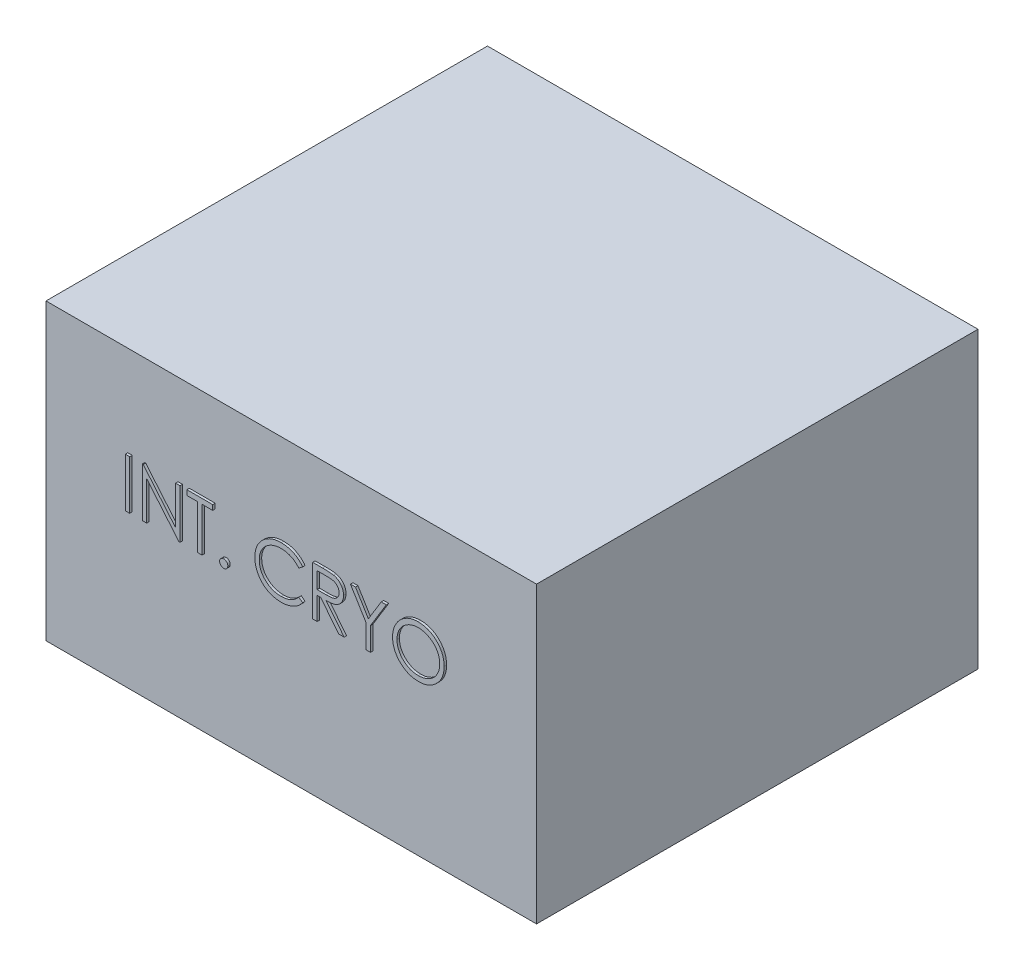
from build123d import *

# Parameters (mm, degrees)
SKETCH1_W           = 1000
SKETCH1_H           = 600
BOSS_EXTRUDE1_DEPTH = 900
SKETCH2_W           = 8.974358974
SKETCH2_H           = 100
BOSS_EXTRUDE2_DEPTH = 5


with BuildPart() as part:
    # Sketch1 → Boss-Extrude1 (new body)
    with BuildSketch(Plane.XY):
        with Locations((-500, -300)):
            Rectangle(SKETCH1_W, SKETCH1_H)
    extrude(amount=BOSS_EXTRUDE1_DEPTH)

    # Sketch2 → Boss-Extrude2 (add)
    with BuildSketch(Plane.XY.offset(900)):
        with Locations((-828.846153846, -234.669187655)):
            Rectangle(SKETCH2_W, SKETCH2_H)
        Polygon((-798.717948718, -284.669187655), (-798.717948718, -184.669187655), (-796.834935897, -184.669187655), (-730.769230769, -263.375117142), (-730.769230769, -184.669187655), (-721.794871795, -184.669187655), (-721.794871795, -284.669187655), (-723.838141026, -284.669187655), (-789.743589744, -206.143546629), (-789.743589744, -284.669187655), align=None)
        Polygon((-707.692307692, -194.925597911), (-707.692307692, -184.669187655), (-655.128205128, -184.669187655), (-655.128205128, -194.925597911), (-676.923076923, -194.925597911), (-676.923076923, -284.669187655), (-685.897435897, -284.669187655), (-685.897435897, -194.925597911), align=None)
        with BuildLine():
            add(Edge.make_bspline(
                [(-632.692307692, -269.28457227), (-632.135444487, -269.317662747), (-631.043779276, -269.382532758), (-629.465518467, -269.82758058), (-628.037099618, -270.617828022), (-626.764749767, -271.671050261), (-625.715993295, -272.948069207), (-624.897583234, -274.365095171), (-624.456412228, -275.956569245), (-624.392014748, -277.054559958), (-624.358974359, -277.617905603)],
                knots=[0, 0, 0, 0, 0.001670366, 0.003274556, 0.004870094, 0.006534684, 0.008199274, 0.009804465, 0.011408656, 0.013098962, 0.013098962, 0.013098962, 0.013098962], degree=3))
            add(Edge.make_bspline(
                [(-624.358974359, -277.617905603), (-624.39313438, -278.167715025), (-624.460497441, -279.251931131), (-624.896571959, -280.831401491), (-625.722230537, -282.249313048), (-626.757516049, -283.543659851), (-628.03741415, -284.599113297), (-629.468895477, -285.382637432), (-631.040074281, -285.859551144), (-632.134826377, -285.92030249), (-632.692307692, -285.951238937)],
                knots=[0, 0, 0, 0, 0.001650427, 0.003254618, 0.004859809, 0.006539876, 0.008204466, 0.009800004, 0.011409813, 0.013080178, 0.013080178, 0.013080178, 0.013080178], degree=3))
            add(Edge.make_bspline(
                [(-632.692307692, -285.951238937), (-633.250190711, -285.921421875), (-634.3393245, -285.863211159), (-635.904638621, -285.372845265), (-637.344837723, -284.606460687), (-638.62448663, -283.541691844), (-639.668442961, -282.255973462), (-640.457739614, -280.821636421), (-640.93174387, -279.256452495), (-640.994083089, -278.168605556), (-641.025641026, -277.617905603)],
                knots=[0, 0, 0, 0, 0.001670366, 0.003260991, 0.004874162, 0.006538752, 0.008218819, 0.009814357, 0.011424166, 0.013074593, 0.013074593, 0.013074593, 0.013074593], degree=3))
            add(Edge.make_bspline(
                [(-641.025641026, -277.617905603), (-640.995295333, -277.053637614), (-640.936049091, -275.951973614), (-640.456744513, -274.374856257), (-639.67456703, -272.941472278), (-638.61727003, -271.672998561), (-637.34514729, -270.610504199), (-635.908112857, -269.837224395), (-634.335554562, -269.378926904), (-633.249556322, -269.316569282), (-632.692307692, -269.28457227)],
                knots=[0, 0, 0, 0, 0.001690306, 0.003300116, 0.004895653, 0.006560243, 0.008224833, 0.009838004, 0.011422943, 0.013093309, 0.013093309, 0.013093309, 0.013093309], degree=3))
        make_face()
        with BuildLine():
            Line((-471.794871795, -203.018546629), (-479.647435897, -209.028162014))
            add(Edge.make_bspline(
                [(-479.647435897, -209.028162014), (-480.207604136, -208.360562876), (-481.320388331, -207.034365284), (-483.11065126, -205.172092584), (-484.976412486, -203.427370829), (-486.916958806, -201.791888554), (-488.967219363, -200.322838105), (-491.077527897, -198.943663735), (-493.283186331, -197.707442651), (-496.333235892, -196.20850019), (-500.323174415, -194.644324333), (-505.345884102, -193.332803439), (-510.589058345, -192.497912705), (-514.16613262, -192.407488663), (-515.985576923, -192.361495347)],
                knots=[0, 0, 0, 0, 0.002613856, 0.005192473, 0.007743552, 0.010275052, 0.012799409, 0.015305337, 0.017834775, 0.020379083, 0.025497771, 0.030657998, 0.035927608, 0.041382546, 0.041382546, 0.041382546, 0.041382546], degree=3))
            add(Edge.make_bspline(
                [(-515.985576923, -192.361495347), (-516.987956904, -192.373037133), (-518.983413835, -192.396013586), (-521.944798792, -192.699131449), (-524.850885967, -193.125166022), (-527.699785002, -193.757318114), (-530.487869532, -194.556535802), (-533.233366734, -195.511547628), (-535.896526728, -196.693114482), (-538.514190677, -197.999064766), (-541.022168134, -199.474134616), (-543.395169499, -201.083087527), (-545.624540011, -202.807918854), (-547.712043215, -204.655093322), (-549.659813167, -206.616292192), (-551.453736333, -208.712416238), (-553.087605198, -210.936764053), (-554.593805914, -213.260004268), (-555.942741152, -215.675369744), (-557.072166278, -218.191800328), (-558.072312627, -220.766203271), (-558.863719559, -223.427665009), (-559.490134326, -226.157458319), (-559.922353277, -228.962909404), (-560.222023882, -231.838157392), (-560.244886079, -233.786994895), (-560.256410256, -234.769347911)],
                knots=[0, 0, 0, 0, 0.003005876, 0.005983854, 0.008921744, 0.011813723, 0.014730434, 0.017619498, 0.020526078, 0.023464515, 0.026391663, 0.029247478, 0.032060323, 0.034841822, 0.037603994, 0.040346045, 0.04311054, 0.045877648, 0.048648306, 0.051400362, 0.054145923, 0.056928071, 0.059722309, 0.062541424, 0.065439641, 0.068385442, 0.068385442, 0.068385442, 0.068385442], degree=3))
            add(Edge.make_bspline(
                [(-560.256410256, -234.769347911), (-560.220358284, -236.247385623), (-560.149575019, -239.149316619), (-559.519622617, -243.399905492), (-558.562334294, -247.471924742), (-557.127603525, -251.339920237), (-555.358487794, -255.05158761), (-553.123041751, -258.544126279), (-550.533997827, -261.870313836), (-547.554728699, -264.951540915), (-544.2859911, -267.76621878), (-540.778907911, -270.244806824), (-537.042213974, -272.310946323), (-533.117167398, -274.03025908), (-528.973564143, -275.35187987), (-524.618855502, -276.282283399), (-520.062512781, -276.889202843), (-516.949101356, -276.947308217), (-515.364583333, -276.976879962)],
                knots=[0, 0, 0, 0, 0.004431613, 0.008700885, 0.012864709, 0.016958508, 0.021052943, 0.025176628, 0.029372183, 0.03367912, 0.038011651, 0.042296543, 0.046538138, 0.050799366, 0.055132591, 0.059560761, 0.064144995, 0.068896013, 0.068896013, 0.068896013, 0.068896013], degree=3))
            add(Edge.make_bspline(
                [(-515.364583333, -276.976879962), (-513.618792219, -276.928629112), (-510.182657679, -276.833659897), (-505.143571212, -276.029109922), (-500.319692194, -274.724597984), (-495.71076115, -272.898943061), (-491.329771258, -270.52564912), (-487.169866678, -267.648566909), (-483.227536092, -264.24032883), (-480.856928028, -261.637953737), (-479.647435897, -260.310213296)],
                knots=[0, 0, 0, 0, 0.005234847, 0.010303431, 0.015264994, 0.020201259, 0.0251398, 0.030179682, 0.035348806, 0.040733293, 0.040733293, 0.040733293, 0.040733293], degree=3))
            Line((-479.647435897, -260.310213296), (-471.794871795, -266.259732527))
            add(Edge.make_bspline(
                [(-471.794871795, -266.259732527), (-472.426817791, -267.075116867), (-473.687682799, -268.701979904), (-475.729340427, -270.995457324), (-477.880120353, -273.152715481), (-480.155997782, -275.156361802), (-482.530791827, -277.046489391), (-485.047143608, -278.769398856), (-487.671973108, -280.349138407), (-490.396386791, -281.795621964), (-493.217490014, -283.078971879), (-496.131902441, -284.177650959), (-499.127061741, -285.124076374), (-502.203104839, -285.902703138), (-505.366412177, -286.510448391), (-508.605568579, -286.916724816), (-511.927565014, -287.195065228), (-514.168748475, -287.220434251), (-515.304487179, -287.233290219)],
                knots=[0, 0, 0, 0, 0.003094093, 0.006173365, 0.009204632, 0.012227349, 0.015265161, 0.018304559, 0.021369005, 0.024451598, 0.027553463, 0.030660046, 0.033789793, 0.036972117, 0.040174051, 0.043446395, 0.046761927, 0.050168318, 0.050168318, 0.050168318, 0.050168318], degree=3))
            add(Edge.make_bspline(
                [(-515.304487179, -287.233290219), (-516.380020524, -287.225804717), (-518.506754527, -287.211003065), (-521.646718859, -286.971226853), (-524.703564024, -286.644091513), (-527.668553335, -286.15151634), (-530.557866908, -285.570249481), (-533.345312179, -284.79107072), (-536.058318189, -283.918237389), (-538.685985066, -282.892380625), (-541.230547917, -281.734775409), (-543.683799671, -280.426445155), (-546.044612025, -278.978391879), (-548.336195478, -277.422534438), (-550.524697869, -275.708897242), (-552.629084307, -273.861279113), (-554.661155057, -271.885907378), (-555.918374628, -270.461482996), (-556.550480769, -269.74530945)],
                knots=[0, 0, 0, 0, 0.00322572, 0.006378462, 0.009442318, 0.01244579, 0.015392341, 0.018278973, 0.021123312, 0.023939366, 0.026736187, 0.029505324, 0.032274388, 0.035041423, 0.037810342, 0.040606877, 0.043439979, 0.046304772, 0.046304772, 0.046304772, 0.046304772], degree=3))
            add(Edge.make_bspline(
                [(-556.550480769, -269.74530945), (-557.562927726, -268.501275481), (-559.575598493, -266.028226612), (-562.150618023, -262.020055719), (-564.354833886, -257.835249751), (-566.137003051, -253.451823214), (-567.530223998, -248.87961215), (-568.495401001, -244.116311739), (-569.1225897, -239.166370533), (-569.194312237, -235.799605142), (-569.230769231, -234.088258168)],
                knots=[0, 0, 0, 0, 0.004808736, 0.009559416, 0.014263537, 0.018980436, 0.023733143, 0.028581148, 0.033545542, 0.038677658, 0.038677658, 0.038677658, 0.038677658], degree=3))
            add(Edge.make_bspline(
                [(-569.230769231, -234.088258168), (-569.186335129, -232.289530924), (-569.098913808, -228.750647365), (-568.356176795, -223.557105842), (-567.161354046, -218.581351589), (-565.464300087, -213.832673172), (-563.312718621, -209.286093737), (-560.654815368, -204.976345027), (-557.521468447, -200.875865037), (-553.937252228, -197.046872143), (-550.006756934, -193.545747782), (-545.797647965, -190.465570532), (-541.318163766, -187.902212932), (-536.617653718, -185.759465434), (-531.660919959, -184.112480773), (-526.458537984, -182.959532582), (-521.020283276, -182.241900688), (-517.309928258, -182.151180462), (-515.424679487, -182.105085091)],
                knots=[0, 0, 0, 0, 0.005393981, 0.010612321, 0.015704128, 0.020722226, 0.025713143, 0.03076698, 0.035883355, 0.041170033, 0.046476826, 0.051653668, 0.056787035, 0.06193305, 0.067127496, 0.072424753, 0.077898527, 0.083552677, 0.083552677, 0.083552677, 0.083552677], degree=3))
            add(Edge.make_bspline(
                [(-515.424679487, -182.105085091), (-514.275694574, -182.118860468), (-512.001394652, -182.146127439), (-508.637033154, -182.412017213), (-505.361538099, -182.855263106), (-502.172652898, -183.458579386), (-499.054863863, -184.207359999), (-496.031999838, -185.182797094), (-493.086323071, -186.29812656), (-490.236411409, -187.582654159), (-487.495938547, -189.024561056), (-484.865758018, -190.607864586), (-482.366762055, -192.330601886), (-479.981366386, -194.178121183), (-477.749474641, -196.189508592), (-475.607718111, -198.309439905), (-473.628830164, -200.598977738), (-472.407310307, -202.210547279), (-471.794871795, -203.018546629)],
                knots=[0, 0, 0, 0, 0.003446444, 0.00682189, 0.010116721, 0.013358015, 0.016554933, 0.019728922, 0.022880073, 0.02600019, 0.029100501, 0.032164947, 0.035204345, 0.038201664, 0.041209409, 0.044212346, 0.04723692, 0.050278166, 0.050278166, 0.050278166, 0.050278166], degree=3))
        make_face()
        with BuildLine():
            Line((-451.282051282, -184.669187655), (-431.270032051, -184.669187655))
            add(Edge.make_bspline(
                [(-431.270032051, -184.669187655), (-429.934571237, -184.673632969), (-427.370338539, -184.682168464), (-423.696816529, -184.72976169), (-420.358899472, -184.866171853), (-417.358332634, -184.983559952), (-414.695171063, -185.197615419), (-412.361248471, -185.402205336), (-410.367314256, -185.670024216), (-409.160289933, -185.918750586), (-408.613782051, -186.031367142)],
                knots=[0, 0, 0, 0, 0.00400646, 0.007692848, 0.01102034, 0.014028417, 0.0167002, 0.019034343, 0.021057084, 0.02273069, 0.02273069, 0.02273069, 0.02273069], degree=3))
            add(Edge.make_bspline(
                [(-408.613782051, -186.031367142), (-407.882164219, -186.212131867), (-406.434535948, -186.569805114), (-404.350248347, -187.325793709), (-402.364124806, -188.200640127), (-400.484415539, -189.228174993), (-398.720535791, -190.416025841), (-397.05429834, -191.743686482), (-395.478142243, -193.203892361), (-394.055809952, -194.833459261), (-392.71469419, -196.543073823), (-391.583590575, -198.39175259), (-390.608548297, -200.324939091), (-389.832247812, -202.362293884), (-389.207162855, -204.484058794), (-388.766413159, -206.709452986), (-388.502093512, -209.028337989), (-388.475183354, -210.609992526), (-388.461538462, -211.411976116)],
                knots=[0, 0, 0, 0, 0.002259452, 0.004470704, 0.006640925, 0.008765645, 0.010888002, 0.01301225, 0.015152307, 0.017323268, 0.019494875, 0.021662876, 0.023812942, 0.025981775, 0.028194116, 0.03044128, 0.032779545, 0.035184726, 0.035184726, 0.035184726, 0.035184726], degree=3))
            add(Edge.make_bspline(
                [(-388.461538462, -211.411976116), (-388.503509836, -212.744407677), (-388.585406859, -215.344326759), (-389.348981249, -219.117494799), (-390.599738956, -222.637189503), (-392.323261499, -225.898979158), (-394.518103662, -228.839283311), (-397.155954837, -231.421867749), (-400.238286594, -233.583008108), (-403.10769562, -235.081659671), (-405.64238704, -236.04145706), (-407.72905312, -236.716781599), (-410.005252477, -237.238552036), (-412.449176323, -237.705984372), (-415.070995051, -238.058889927), (-417.864424748, -238.317364054), (-420.831457652, -238.478908303), (-422.869716776, -238.502965585), (-423.918269231, -238.515341501)],
                knots=[0, 0, 0, 0, 0.003993619, 0.007792586, 0.011492826, 0.015166947, 0.018816795, 0.022457397, 0.026192609, 0.030072058, 0.032133024, 0.034318722, 0.036646063, 0.039133024, 0.04178188, 0.044578486, 0.047547558, 0.050693164, 0.050693164, 0.050693164, 0.050693164], degree=3))
            Line((-423.918269231, -238.515341501), (-387.179487179, -284.669187655))
            Line((-387.179487179, -284.669187655), (-398.27724359, -284.669187655))
            Line((-398.27724359, -284.669187655), (-435.016025641, -238.515341501))
            Line((-435.016025641, -238.515341501), (-442.307692308, -238.515341501))
            Line((-442.307692308, -238.515341501), (-442.307692308, -284.669187655))
            Line((-442.307692308, -284.669187655), (-451.282051282, -284.669187655))
            Line((-451.282051282, -284.669187655), (-451.282051282, -184.669187655))
        make_face()
        with BuildLine():
            Line((-442.307692308, -194.925597911), (-442.307692308, -228.258931244))
            Line((-442.307692308, -228.258931244), (-423.998397436, -228.399155603))
            add(Edge.make_bspline(
                [(-423.998397436, -228.399155603), (-423.143539181, -228.399533794), (-421.486580406, -228.400266834), (-419.089418554, -228.286158941), (-416.857415363, -228.156349848), (-414.799108159, -227.957797119), (-412.913577435, -227.701909355), (-411.201765629, -227.381824091), (-409.660878432, -227.008908016), (-407.863777334, -226.431718707), (-405.857019295, -225.517261042), (-403.676120441, -224.186818222), (-401.818910791, -222.513414817), (-400.249829011, -220.599887502), (-398.988988112, -218.495994678), (-398.100072274, -216.226955558), (-397.536002494, -213.850052758), (-397.469472624, -212.216392533), (-397.435897436, -211.391944065)],
                knots=[0, 0, 0, 0, 0.002564181, 0.004970113, 0.007198088, 0.00927109, 0.011172025, 0.012904653, 0.014493385, 0.015925082, 0.018561105, 0.021090067, 0.023558809, 0.026021122, 0.028491245, 0.030883126, 0.033307997, 0.035778527, 0.035778527, 0.035778527, 0.035778527], degree=3))
            add(Edge.make_bspline(
                [(-397.435897436, -211.391944065), (-397.470243753, -210.587756244), (-397.53830562, -208.994149425), (-398.093984721, -206.661123417), (-399.033681331, -204.459210556), (-400.300030986, -202.397368127), (-401.842863985, -200.525775674), (-403.651944348, -198.924428444), (-405.677807066, -197.603015168), (-407.571269876, -196.758604296), (-409.263675947, -196.240894203), (-410.733094806, -195.876575237), (-412.393422741, -195.583876125), (-414.252721558, -195.3493601), (-416.303053866, -195.147790264), (-418.554786754, -195.01202516), (-420.992980476, -194.931629042), (-422.682892796, -194.927655074), (-423.557692308, -194.925597911)],
                knots=[0, 0, 0, 0, 0.002410597, 0.004776925, 0.007146895, 0.009565553, 0.012012417, 0.014396315, 0.01678551, 0.019242521, 0.020585714, 0.022091853, 0.023781447, 0.025640006, 0.027713009, 0.029960977, 0.0324062, 0.035030475, 0.035030475, 0.035030475, 0.035030475], degree=3))
            Line((-423.557692308, -194.925597911), (-442.307692308, -194.925597911))
        make_face(mode=Mode.SUBTRACT)
        Polygon((-374.358974359, -184.669187655), (-364.082532051, -184.669187655), (-337.800480769, -227.637937655), (-311.55849359, -184.669187655), (-301.282051282, -184.669187655), (-333.333333333, -237.133129962), (-333.333333333, -284.669187655), (-342.307692308, -284.669187655), (-342.307692308, -237.133129962), align=None)
        with BuildLine():
            add(Edge.make_bspline(
                [(-236.538461538, -182.105085091), (-234.68680137, -182.151984501), (-231.049988028, -182.244098813), (-225.70499095, -182.949216058), (-220.602273942, -184.169084342), (-215.700269976, -185.793740985), (-211.057613503, -187.961009138), (-206.639359432, -190.580584805), (-202.45602018, -193.679912198), (-198.563980707, -197.235032965), (-195.002353556, -201.103131648), (-191.864471092, -205.231071936), (-189.234691271, -209.593894859), (-187.075097352, -214.17849002), (-185.38085136, -218.974489105), (-184.211735826, -224.007460612), (-183.464931536, -229.244794614), (-183.37762361, -232.816990749), (-183.333333333, -234.629123552)],
                knots=[0, 0, 0, 0, 0.005554083, 0.010908677, 0.01613685, 0.021274319, 0.026374041, 0.031475768, 0.036660162, 0.041963929, 0.047266409, 0.052414686, 0.057492327, 0.062519454, 0.067594209, 0.072720301, 0.077998167, 0.083432172, 0.083432172, 0.083432172, 0.083432172], degree=3))
            add(Edge.make_bspline(
                [(-183.333333333, -234.629123552), (-183.37761712, -236.427907734), (-183.464905593, -239.973519746), (-184.212584951, -245.177618151), (-185.38518495, -250.180209479), (-187.059363984, -254.972942416), (-189.208663369, -259.560872809), (-191.855953973, -263.931928634), (-194.97427428, -268.087542874), (-198.523041452, -271.982190451), (-202.391642652, -275.553546757), (-206.541078847, -278.665514634), (-210.878030845, -281.343346765), (-215.458308221, -283.480023164), (-220.221166416, -285.18779232), (-225.20923279, -286.352153178), (-230.399134334, -287.103211556), (-233.938305871, -287.189454869), (-235.737179487, -287.233290219)],
                knots=[0, 0, 0, 0, 0.005393981, 0.010632161, 0.015738763, 0.020787992, 0.025833246, 0.030910887, 0.036091177, 0.041394944, 0.046697425, 0.051861694, 0.056932613, 0.06195974, 0.066996716, 0.072083831, 0.077302171, 0.082696152, 0.082696152, 0.082696152, 0.082696152], degree=3))
            add(Edge.make_bspline(
                [(-235.737179487, -287.233290219), (-237.549302887, -287.189022023), (-241.121480485, -287.101757625), (-246.365395781, -286.353717488), (-251.401902748, -285.183965951), (-256.216598497, -283.512267773), (-260.812167915, -281.351775467), (-265.197598849, -278.717364636), (-269.35528877, -275.591446317), (-273.250767241, -272.0438299), (-276.815030046, -268.181785557), (-279.92244078, -264.043663983), (-282.557444018, -259.710650936), (-284.710682089, -255.170721676), (-286.415380928, -250.445823313), (-287.578375731, -245.504438242), (-288.330831505, -240.374738076), (-288.417541404, -236.882083838), (-288.461538462, -235.109892783)],
                knots=[0, 0, 0, 0, 0.005434005, 0.010711871, 0.015857458, 0.020925606, 0.02597086, 0.031065661, 0.036245951, 0.041549718, 0.046852199, 0.051988418, 0.05704892, 0.062039837, 0.067039068, 0.072087224, 0.077246051, 0.082559985, 0.082559985, 0.082559985, 0.082559985], degree=3))
            add(Edge.make_bspline(
                [(-288.461538462, -235.109892783), (-288.446263161, -233.92038795), (-288.415905266, -231.556384422), (-288.050428338, -228.045910132), (-287.520094018, -224.591891338), (-286.760039374, -221.204149968), (-285.765991746, -217.890978976), (-284.593076677, -214.62952861), (-283.160509667, -211.452850788), (-281.54106258, -208.345896739), (-279.733582351, -205.35709943), (-277.737132367, -202.531968483), (-275.621836125, -199.846797146), (-273.302882021, -197.371168465), (-270.856697873, -195.033063997), (-268.243601354, -192.868414939), (-265.47953723, -190.857702054), (-262.552612094, -189.045692309), (-259.534947097, -187.406859892), (-256.424182018, -186.000521292), (-253.262565689, -184.793490963), (-250.035290034, -183.815181672), (-246.750925117, -183.042837786), (-243.402302701, -182.516913395), (-239.992090521, -182.150504312), (-237.694624266, -182.12028997), (-236.538461538, -182.105085091)],
                knots=[0, 0, 0, 0, 0.003567112, 0.007089222, 0.010576929, 0.014046871, 0.017494829, 0.020948542, 0.024436766, 0.027940142, 0.031454669, 0.034905883, 0.038312805, 0.041700591, 0.045072885, 0.048458479, 0.051872401, 0.055318671, 0.058778364, 0.062167038, 0.065552633, 0.068923855, 0.072276636, 0.07566543, 0.079087863, 0.082554855, 0.082554855, 0.082554855, 0.082554855], degree=3))
        make_face()
        with BuildLine():
            add(Edge.make_bspline(
                [(-236.09775641, -192.361495347), (-237.04674594, -192.37306364), (-238.935652595, -192.396089632), (-241.743782202, -192.699395791), (-244.514980312, -193.131678333), (-247.249819231, -193.748293212), (-249.93685607, -194.588409006), (-252.601137247, -195.555292097), (-255.218367357, -196.733037543), (-257.779906153, -198.063686239), (-260.263194015, -199.536512548), (-262.606414056, -201.16427732), (-264.815632455, -202.908807441), (-266.885440074, -204.774174224), (-268.809759279, -206.769877132), (-270.626465035, -208.865661021), (-272.262738796, -211.121429337), (-273.762326705, -213.47601239), (-275.104264999, -215.926343282), (-276.297560848, -218.446625061), (-277.273675385, -221.057416111), (-278.069743279, -223.730392042), (-278.729737875, -226.461319461), (-279.147849992, -229.270915142), (-279.454488833, -232.1450612), (-279.476198703, -234.087399887), (-279.487179487, -235.06982868)],
                knots=[0, 0, 0, 0, 0.00284568, 0.005664154, 0.008463486, 0.011257723, 0.014064857, 0.016904183, 0.019755779, 0.022667671, 0.025560343, 0.028410954, 0.031220374, 0.034000285, 0.036762748, 0.039533044, 0.042313677, 0.045114514, 0.047902713, 0.050689761, 0.053472775, 0.056254923, 0.059053681, 0.061892584, 0.064770863, 0.067716664, 0.067716664, 0.067716664, 0.067716664], degree=3))
            add(Edge.make_bspline(
                [(-279.487179487, -235.06982868), (-279.45075486, -236.51446356), (-279.379096349, -239.356507282), (-278.751737203, -243.521311393), (-277.785395076, -247.52383386), (-276.360898892, -251.342174126), (-274.579452759, -255.009153635), (-272.378684466, -258.492242341), (-269.771282021, -261.792381608), (-266.809466975, -264.88653215), (-263.571675358, -267.710697985), (-260.13359736, -270.189652518), (-256.532065717, -272.287088227), (-252.757688497, -273.995804581), (-248.830615953, -275.34979709), (-244.725543067, -276.277757979), (-240.46981565, -276.888485275), (-237.568939788, -276.947135445), (-236.09775641, -276.976879962)],
                knots=[0, 0, 0, 0, 0.004331558, 0.008521514, 0.012607512, 0.016663693, 0.0207221, 0.024818152, 0.028997945, 0.033319346, 0.037649838, 0.041869427, 0.046016449, 0.050131268, 0.054280611, 0.058454687, 0.062741031, 0.067151769, 0.067151769, 0.067151769, 0.067151769], degree=3))
            add(Edge.make_bspline(
                [(-236.09775641, -276.976879962), (-235.108913507, -276.963294123), (-233.147741039, -276.936349324), (-230.230726115, -276.664958557), (-227.366262923, -276.229762288), (-224.558369212, -275.603172128), (-221.810231743, -274.81896623), (-219.110380226, -273.88731686), (-216.487571931, -272.724996755), (-213.908719422, -271.440769567), (-211.440255374, -269.976765066), (-209.083811594, -268.404246504), (-206.898783599, -266.662285912), (-204.830524415, -264.824634125), (-202.89830473, -262.854238472), (-201.115190895, -260.753660705), (-199.487187119, -258.509641927), (-197.988168644, -256.158630335), (-196.650932566, -253.701594544), (-195.48581545, -251.172175174), (-194.497354998, -248.57660062), (-193.699397717, -245.911127149), (-193.074098811, -243.180817184), (-192.643243957, -240.382014951), (-192.341859996, -237.520319452), (-192.319143505, -235.58478071), (-192.307692308, -234.609091501)],
                knots=[0, 0, 0, 0, 0.002965826, 0.005882124, 0.00878041, 0.011652827, 0.014506252, 0.017350874, 0.020212724, 0.023106368, 0.025988826, 0.028816824, 0.031598107, 0.034364634, 0.037112751, 0.039870052, 0.042622692, 0.045423528, 0.048229303, 0.051007915, 0.053772193, 0.056554341, 0.059348579, 0.062167694, 0.065045973, 0.06797175, 0.06797175, 0.06797175, 0.06797175], degree=3))
            add(Edge.make_bspline(
                [(-192.307692308, -234.609091501), (-192.319152678, -233.640077093), (-192.341886435, -231.717858517), (-192.643099996, -228.876120849), (-193.074554006, -226.097457664), (-193.696345665, -223.392777579), (-194.497778628, -220.761391148), (-195.485988068, -218.205769785), (-196.651282339, -215.716392783), (-197.988660178, -213.299412869), (-199.49196942, -210.980134641), (-201.134662087, -208.762922854), (-202.945100605, -206.68941596), (-204.871558458, -204.708424701), (-206.962155182, -202.862199284), (-209.207420727, -201.150127265), (-211.580097235, -199.530890857), (-214.092303961, -198.070160518), (-216.684988354, -196.721182441), (-219.345387153, -195.565439494), (-222.043361428, -194.58337894), (-224.772050351, -193.745751367), (-227.554421161, -193.134093363), (-230.371673414, -192.699006224), (-233.219909373, -192.396195199), (-235.135429937, -192.373098669), (-236.09775641, -192.361495347)],
                knots=[0, 0, 0, 0, 0.002905752, 0.005764095, 0.008563427, 0.011338137, 0.014081943, 0.016808805, 0.019551075, 0.022321733, 0.02508884, 0.027837249, 0.030592366, 0.033340483, 0.036121983, 0.03895069, 0.041806504, 0.044733653, 0.047663336, 0.050569917, 0.053428049, 0.056273517, 0.059126379, 0.061965282, 0.064823625, 0.067709353, 0.067709353, 0.067709353, 0.067709353], degree=3))
        make_face(mode=Mode.SUBTRACT)
    extrude(amount=BOSS_EXTRUDE2_DEPTH)


solid = part.part
